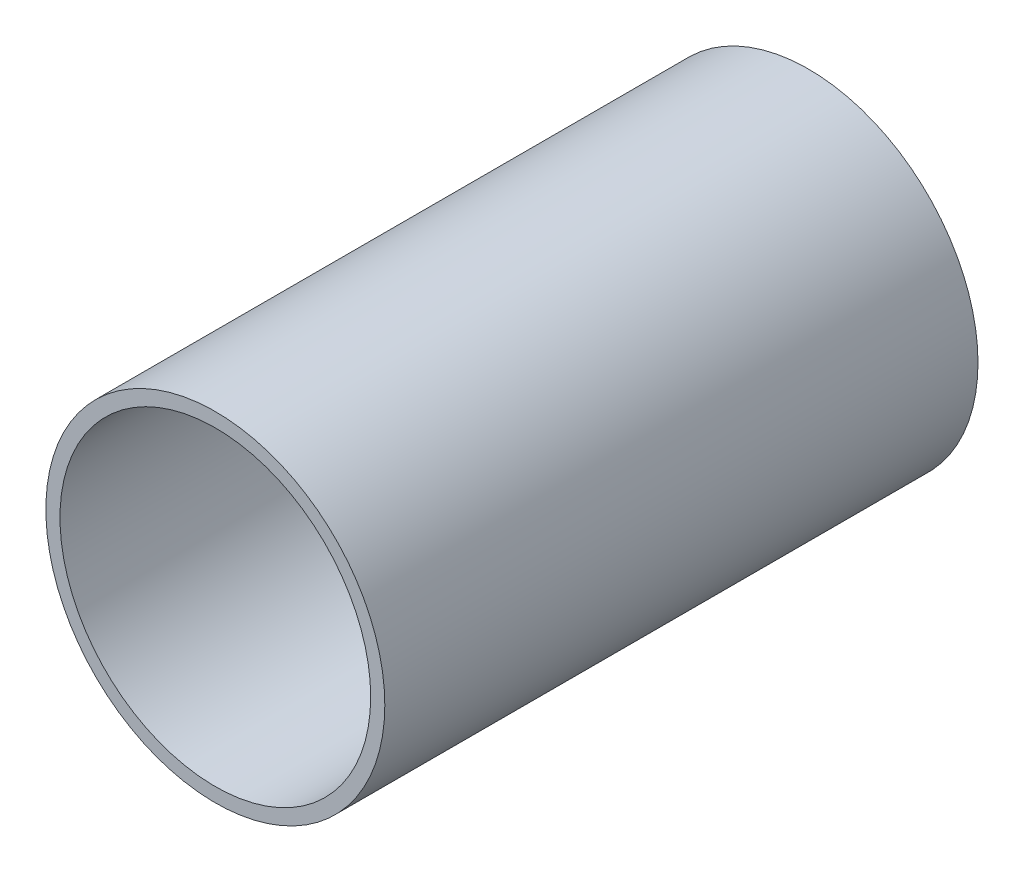
from build123d import *

# Parameters (mm, degrees)
SKETCH1_R           = 12
SKETCH1_R_2         = 11
BOSS_EXTRUDE1_DEPTH = 21


with BuildPart() as part:
    # Sketch1 → Boss-Extrude1 (new body, symmetric)
    with BuildSketch(Plane.XY):
        Circle(SKETCH1_R)
        Circle(SKETCH1_R_2, mode=Mode.SUBTRACT)
    extrude(amount=BOSS_EXTRUDE1_DEPTH, both=True)


solid = part.part
